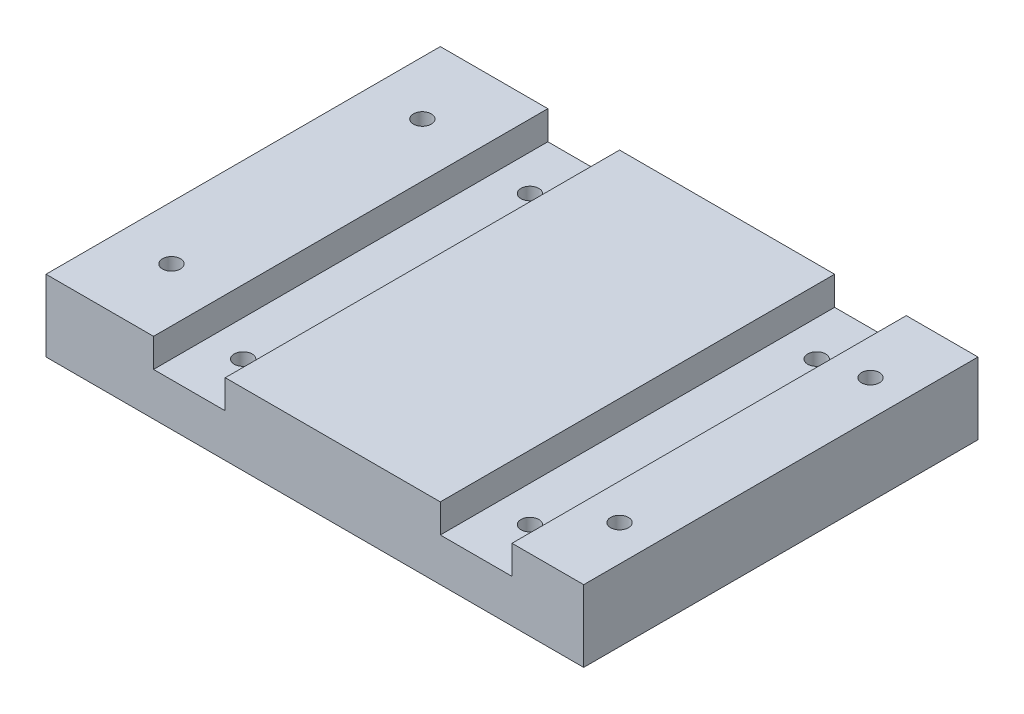
from build123d import *

# Parameters (mm, degrees)
BOSS_EXTRUDE1_DEPTH       = 110
F_5_0MM_DOWEL_HOLE1_D     = 5
F_5_0MM_DOWEL_HOLE2_D     = 5
F_5_0MM_DOWEL_HOLE2_DEPTH = 12


with BuildPart() as part:
    # Sketch1 → Boss-Extrude1 (new body)
    with BuildSketch(Plane.XY):
        Polygon((-74.4140625, 0), (75.5859375, 0), (75.5859375, 20), (55.5859375, 20), (55.5859375, 12), (35.5859375, 12), (35.5859375, 20), (-24.4140625, 20), (-24.4140625, 12), (-44.4140625, 12), (-44.4140625, 20), (-74.4140625, 20), align=None)
    extrude(amount=BOSS_EXTRUDE1_DEPTH)

    # Ø5.0mm Dowel Hole1 (through all)
    with Locations(Plane(origin=(-59.4140625, 20, 20), x_dir=(1, 0, 0), z_dir=(0, 1, 0))):
        with Locations((0, 0), (0, -70), (125, 0), (125, -70)):
            Hole(F_5_0MM_DOWEL_HOLE1_D / 2)

    # Ø5.0mm Dowel Hole2
    with Locations(Plane(origin=(-34.4140625, 12, 15), x_dir=(1, 0, 0), z_dir=(0, 1, 0))):
        with Locations((0, 0), (0, -80), (80, 0), (80, -80)):
            Hole(F_5_0MM_DOWEL_HOLE2_D / 2, depth=F_5_0MM_DOWEL_HOLE2_DEPTH)


solid = part.part
